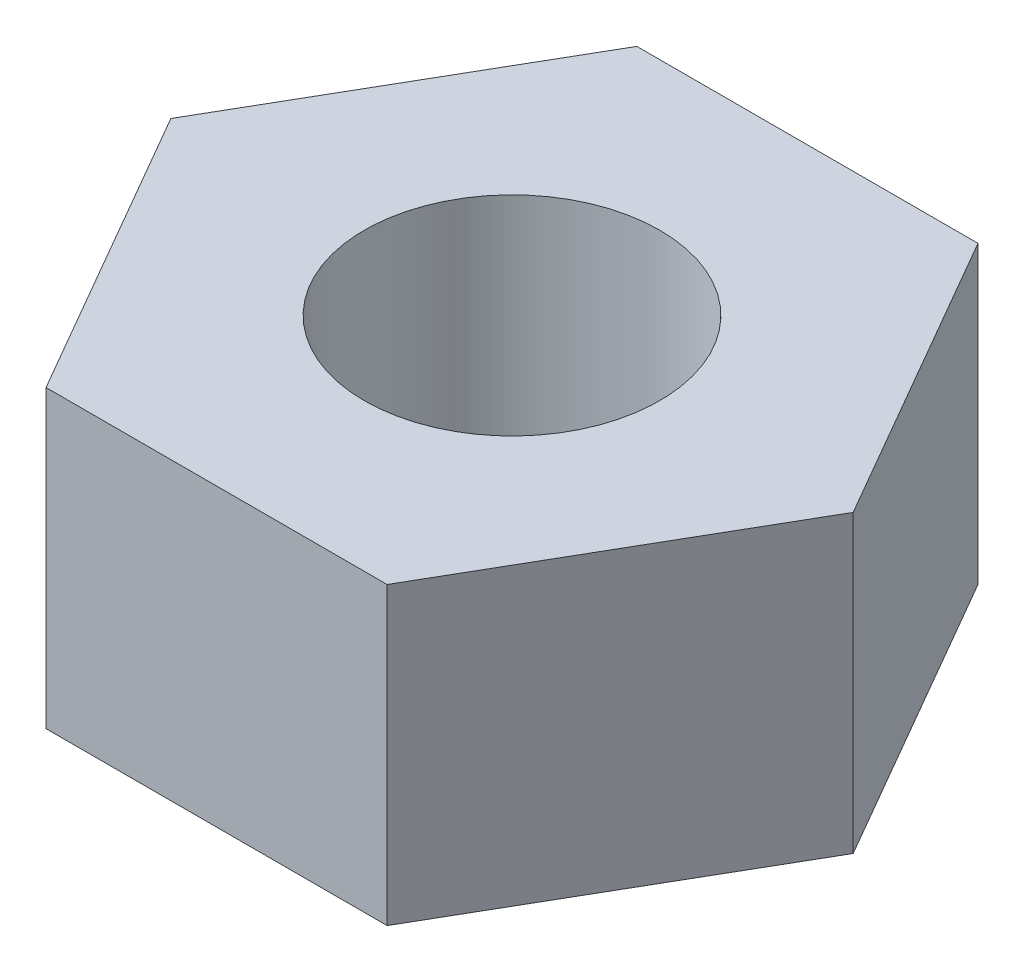
from build123d import *

# Parameters (mm, degrees)
SKETCH1_R           = 5
BOSS_EXTRUDE1_DEPTH = 10


with BuildPart() as part:
    # Sketch1 → Boss-Extrude1 (new body)
    with BuildSketch(Plane(origin=(0, 0, 0), x_dir=(1, 0, 0), z_dir=(0, 1, 0))):
        Polygon((11.547005384, 0), (5.773502692, 10), (-5.773502692, 10), (-11.547005384, 0), (-5.773502692, -10), (5.773502692, -10), align=None)
        Circle(SKETCH1_R, mode=Mode.SUBTRACT)
    extrude(amount=BOSS_EXTRUDE1_DEPTH)


solid = part.part
